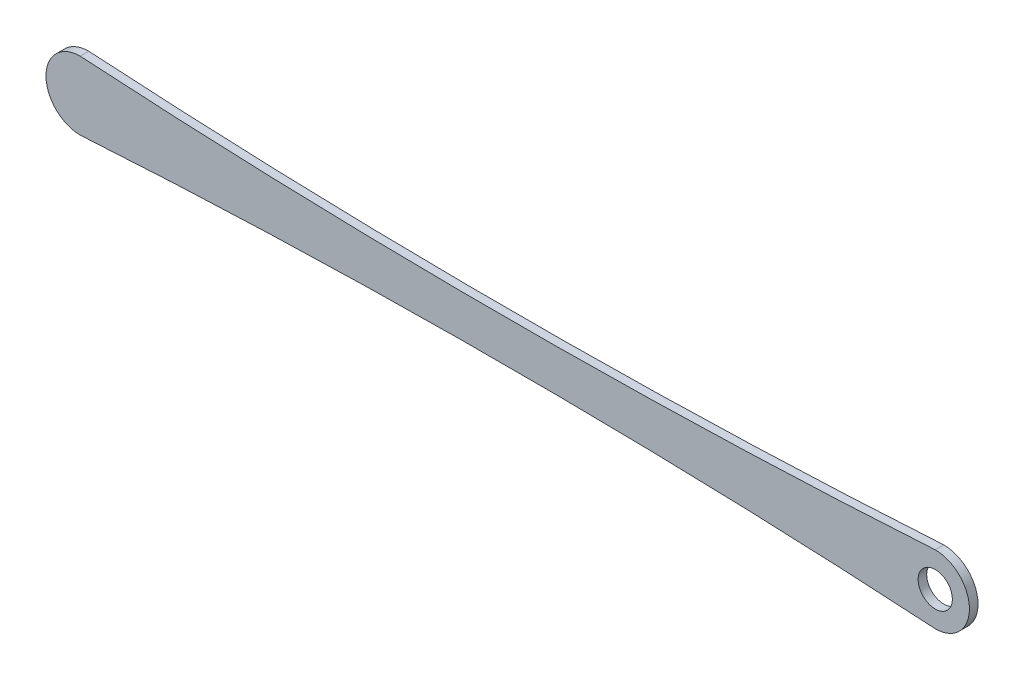
from build123d import *

# Parameters (mm, degrees)
BOSS_EXTRUDE1_DEPTH = 25
SKETCH2_R           = 50
BOSS_EXTRUDE2_DEPTH = 25
SKETCH3_R           = 50
CUT_EXTRUDE2_DEPTH  = 25


with BuildPart() as part:
    # Sketch1 → Boss-Extrude1 (new body)
    with BuildSketch(Plane.XY):
        with BuildLine():
            ThreePointArc((-1250, 100), (-1350, 0), (-1250, -100))
            ThreePointArc((-1250, -100), (0, -60.899278339), (1250, -100))
            ThreePointArc((1250, -100), (1350, 0), (1250, 100))
            ThreePointArc((1250, 100), (0, 60.899278339), (-1250, 100))
        make_face()
    extrude(amount=BOSS_EXTRUDE1_DEPTH)

    # Sketch2 → Boss-Extrude2 (add)
    with BuildSketch(Plane(origin=(0, 0, 0), x_dir=(1, 0, 0), z_dir=(0, 0, -1))):
        with Locations((-1250, 0)):
            Circle(SKETCH2_R)
    extrude(amount=BOSS_EXTRUDE2_DEPTH)

    # Sketch3 → Cut-Extrude2 (cut)
    with BuildSketch(Plane.XY.offset(25)):
        with Locations((1250, 0)):
            Circle(SKETCH3_R)
    extrude(amount=-CUT_EXTRUDE2_DEPTH, mode=Mode.SUBTRACT)


solid = part.part
